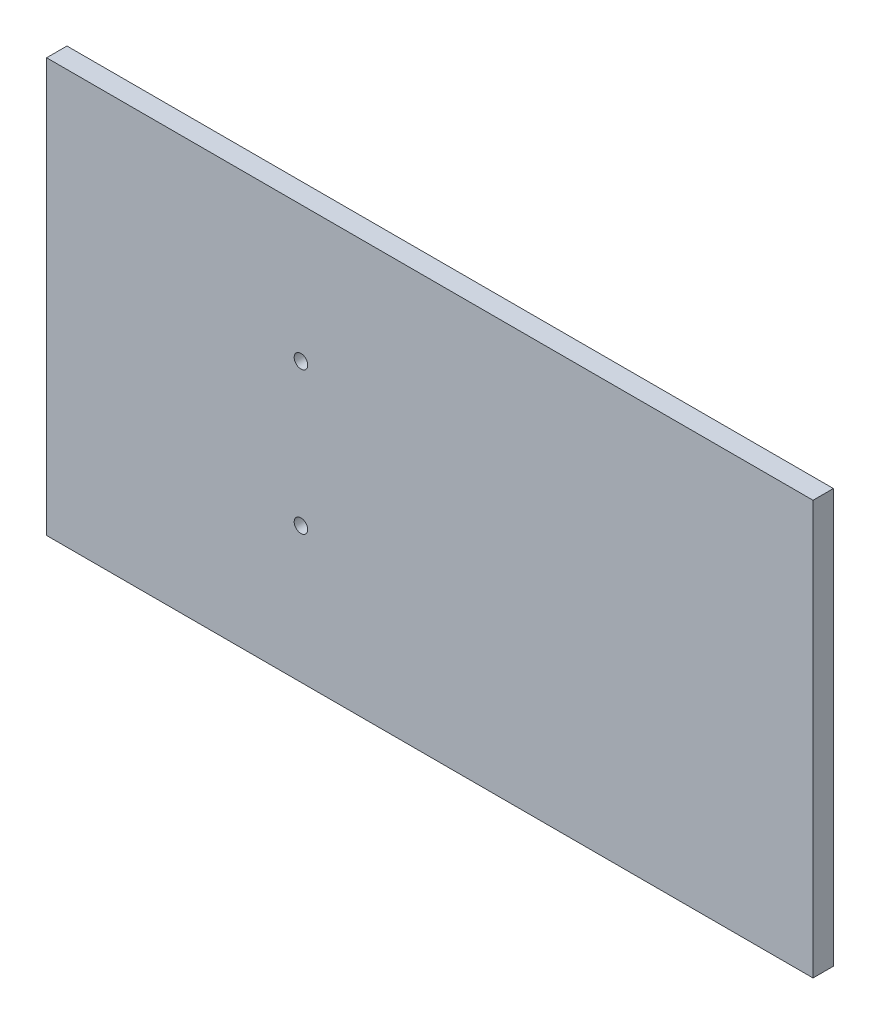
from build123d import *

# Parameters (mm, degrees)
SKETCH1_W           = 113
SKETCH1_H           = 61
SKETCH1_R           = 1
BOSS_EXTRUDE1_DEPTH = 3


with BuildPart() as part:
    # Sketch1 → Boss-Extrude1 (new body)
    with BuildSketch(Plane.XY):
        with Locations((-56.5, 30.5)):
            Rectangle(SKETCH1_W, SKETCH1_H)
        with Locations((-75.5, 41)):
            Circle(SKETCH1_R, mode=Mode.SUBTRACT)
        with Locations((-75.5, 20)):
            Circle(SKETCH1_R, mode=Mode.SUBTRACT)
    extrude(amount=BOSS_EXTRUDE1_DEPTH)


solid = part.part
